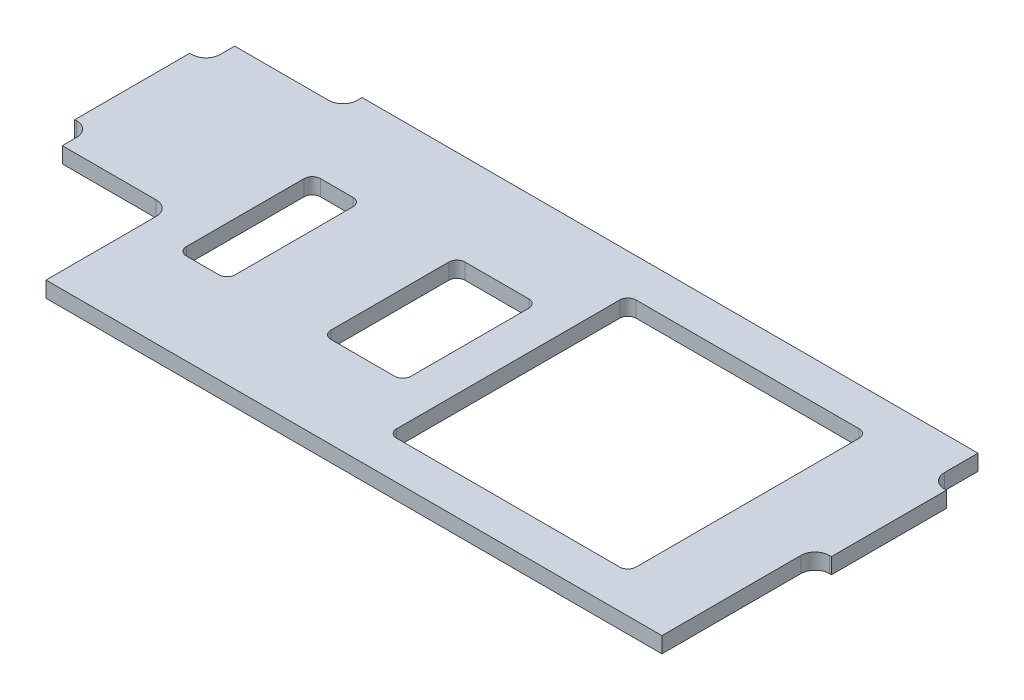
from build123d import *

# Parameters (mm, degrees)
SKIZZE1_W                       = 5.1
SKIZZE1_H                       = 14
SKIZZE1_W_2                     = 8.35
SKIZZE1_W_3                     = 25
SKIZZE1_H_2                     = 25
AUFSATZ_LINEAR_AUSTRAGEN1_DEPTH = 0.825
VERRUNDUNG1_R                   = 1.5
VERRUNDUNG2_R                   = 0.85


with BuildPart() as part:
    # Skizze1 → Aufsatz-Linear austragen1 (new body, symmetric)
    with BuildSketch(Plane(origin=(0, 0, 0), x_dir=(1, 0, 0), z_dir=(0, 1, 0))):
        Polygon((37.8, 11.5), (37.8, 16.5), (-26.5, 16.5), (-26.5, 14.5), (-26.5, -3.5), (-26.5, -16.5), (37.8, -16.5), (37.8, -0.5), (39.5, -0.5), (39.5, 11.5), align=None)
        with Locations((-19.65, 0)):
            Rectangle(SKIZZE1_W, SKIZZE1_H, mode=Mode.SUBTRACT)
        with Locations((-2.925, 0)):
            Rectangle(SKIZZE1_W_2, SKIZZE1_H, mode=Mode.SUBTRACT)
        with Locations((17.75, 0)):
            Rectangle(SKIZZE1_W_3, SKIZZE1_H_2, mode=Mode.SUBTRACT)
        Polygon((-26.5, -3.5), (-26.5, 14.5), (-37.8, 14.5), (-37.8, 11.5), (-39.5, 11.5), (-39.5, -0.5), (-37.8, -0.5), (-37.8, -3.5), align=None)
    extrude(amount=AUFSATZ_LINEAR_AUSTRAGEN1_DEPTH, both=True)

    # Verrundung1
    verrundung1_edges = [part.edges().sort_by_distance(p)[0] for p in [
        (37.8, 0, -11.5),
        (37.8, 0, 0.5),
        (-26.5, 0, 3.5),
        (-37.8, 0, 0.5),
        (-37.8, 0, -11.5),
        (-26.5, 0, -14.5),
    ]]
    fillet(verrundung1_edges, radius=VERRUNDUNG1_R)

    # Verrundung2
    verrundung2_edges = [part.edges().sort_by_distance(p)[0] for p in [
        (-7.1, 0, -7),
        (-7.1, 0, 7),
        (1.25, 0, 7),
        (1.25, 0, -7),
        (5.25, 0, -12.5),
        (5.25, 0, 12.5),
        (30.25, 0, 12.5),
        (30.25, 0, -12.5),
        (-17.1, 0, 7),
        (-17.1, 0, -7),
        (-22.2, 0, -7),
        (-22.2, 0, 7),
    ]]
    fillet(verrundung2_edges, radius=VERRUNDUNG2_R)


solid = part.part
